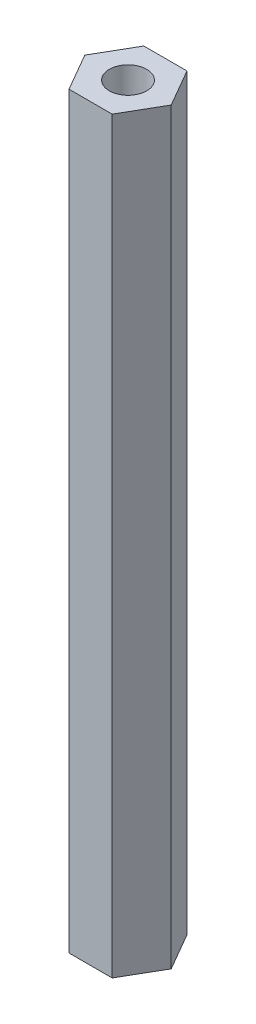
from build123d import *

# Parameters (mm, degrees)
SKETCH1_R           = 3.175
BOSS_EXTRUDE1_DEPTH = 63.5


with BuildPart() as part:
    # Sketch1 → Boss-Extrude1 (new body, symmetric)
    with BuildSketch(Plane(origin=(0, 0, 0), x_dir=(1, 0, 0), z_dir=(0, 1, 0))):
        Polygon((3.666174209, -6.35), (7.332348419, 0), (3.666174209, 6.35), (-3.666174209, 6.35), (-7.332348419, 0), (-3.666174209, -6.35), align=None)
        Circle(SKETCH1_R, mode=Mode.SUBTRACT)
    extrude(amount=BOSS_EXTRUDE1_DEPTH, both=True)


solid = part.part
